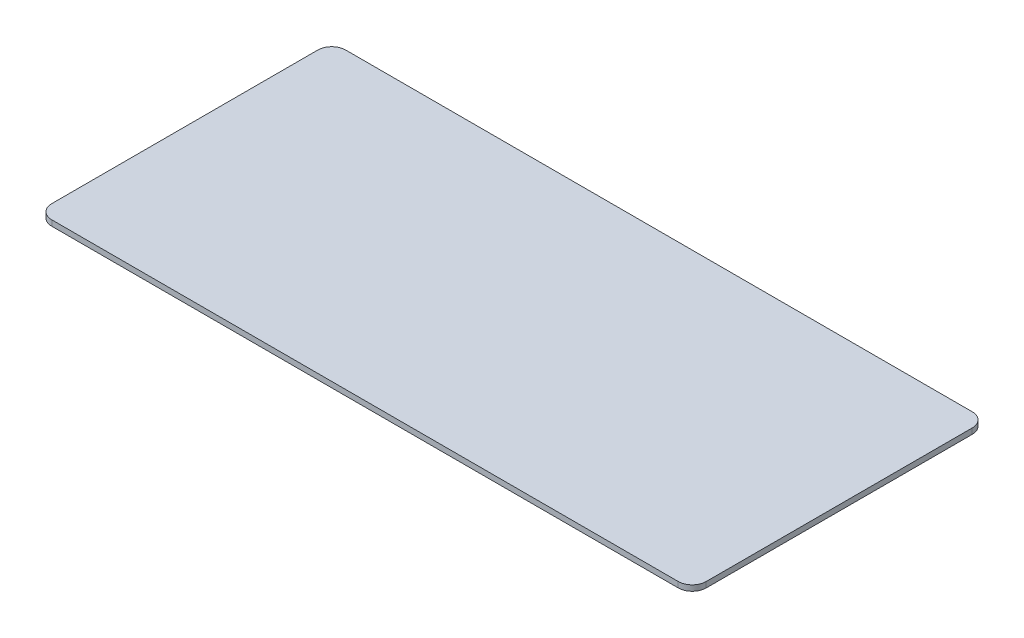
from build123d import *

# Parameters (mm, degrees)
EXTRUDE_1_DEPTH = 0.8


with BuildPart() as part:
    # 草图1 → 凸台-拉伸1 (new body)
    with BuildSketch(Plane(origin=(0, 0, 0), x_dir=(1, 0, 0), z_dir=(0, 1, 0))):
        with BuildLine():
            Line((-71.34309172, -35.060089169), (18.15690828, -35.060089169))
            ThreePointArc((18.15690828, -35.060089169), (19.571121842, -34.474302732), (20.15690828, -33.060089169))
            Line((20.15690828, -33.060089169), (20.15690828, 4.939910831))
            ThreePointArc((20.15690828, 4.939910831), (19.571121842, 6.354124393), (18.15690828, 6.939910831))
            Line((18.15690828, 6.939910831), (-71.34309172, 6.939910831))
            ThreePointArc((-71.34309172, 6.939910831), (-72.757305283, 6.354124393), (-73.34309172, 4.939910831))
            Line((-73.34309172, 4.939910831), (-73.34309172, -33.060089169))
            ThreePointArc((-73.34309172, -33.060089169), (-72.757305283, -34.474302732), (-71.34309172, -35.060089169))
        make_face()
    extrude(amount=EXTRUDE_1_DEPTH)


solid = part.part
